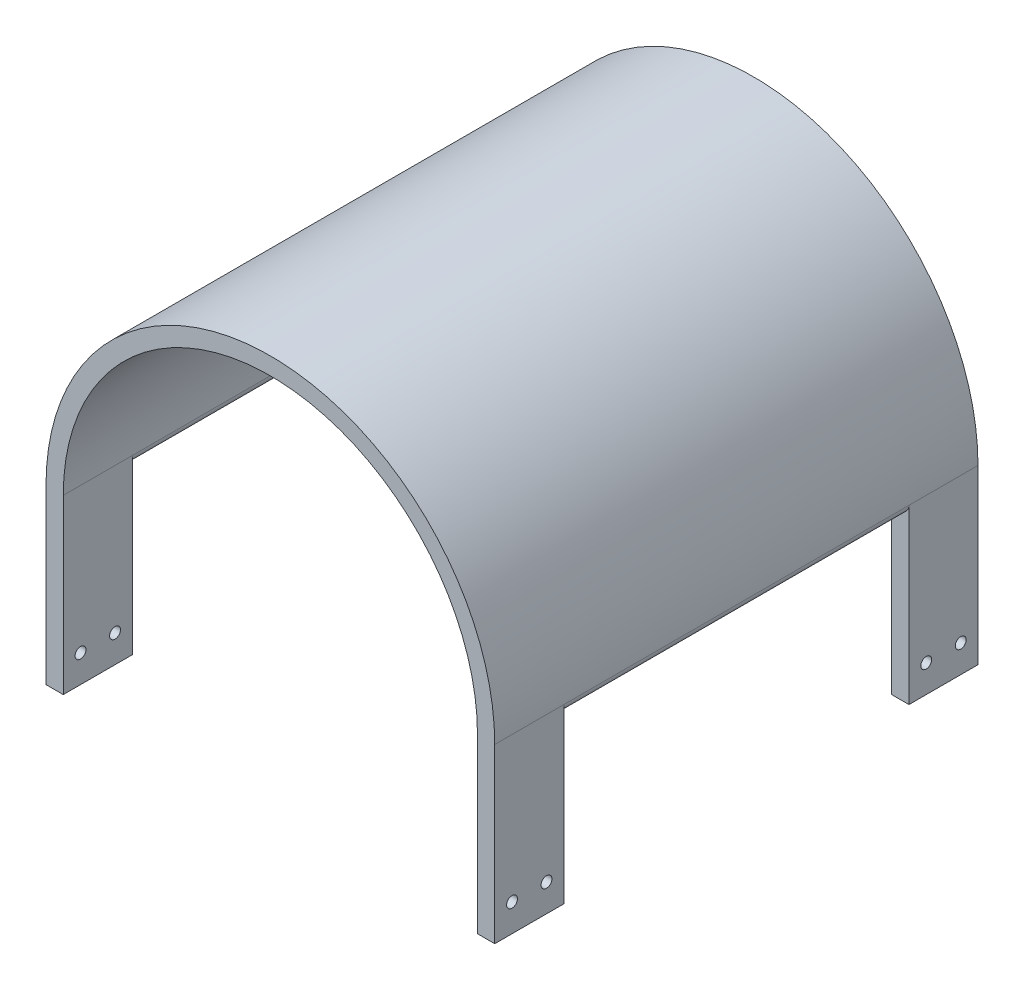
from build123d import *

# Parameters (mm, degrees)
EXTRUDE_THIN1_DEPTH     = 177.8
SKETCH7_W               = 6.35
SKETCH7_H               = 25.4
BOSS_EXTRUDE2_DEPTH     = 63.5
SKETCH11_R              = 2
CUT_EXTRUDE1_DEPTH      = 6.35
MIRROR2_COPY_1_SKETCH_W = 6.35
MIRROR2_COPY_1_SKETCH_H = 25.4
MIRROR2_COPY_1_DEPTH    = 63.5
MIRROR2_COPY_2_SKETCH_R = 2
MIRROR2_COPY_2_DEPTH    = 6.35
BOSS_EXTRUDE3_DEPTH     = 127


with BuildPart() as part:
    # Sketch2 → Extrude-Thin1 (new body)
    with BuildSketch(Plane.XY):
        with BuildLine():
            ThreePointArc((76.2, 23.522786699), (0, 99.722786699), (-76.2, 23.522786699))
            Line((-76.2, 23.522786699), (-82.55, 23.522786699))
            ThreePointArc((-82.55, 23.522786699), (0, 106.072786699), (82.55, 23.522786699))
            Line((82.55, 23.522786699), (76.2, 23.522786699))
        make_face()
    extrude(amount=EXTRUDE_THIN1_DEPTH)

    # Sketch7 → Boss-Extrude2 (add)
    with BuildSketch(Plane.XZ.offset(-23.522786699)):
        with Locations((79.375, 12.7)):
            Rectangle(SKETCH7_W, SKETCH7_H)
    boss_extrude2 = extrude(amount=BOSS_EXTRUDE2_DEPTH)

    # Sketch11 → Cut-Extrude1 (cut)
    with BuildSketch(Plane.ZY.offset(-76.2)):
        with Locations((6.35, -29.817213301)):
            Circle(SKETCH11_R)
        with Locations((19.05, -29.817213301)):
            Circle(SKETCH11_R)
    cut_extrude1 = extrude(amount=-CUT_EXTRUDE1_DEPTH, mode=Mode.SUBTRACT)

    # Mirror1: Boss-Extrude2, Cut-Extrude1 across plane
    add(boss_extrude2.mirror(Plane.XY.offset(88.9)))
    add(cut_extrude1.mirror(Plane.XY.offset(88.9)), mode=Mode.SUBTRACT)

    # Mirror2: Boss-Extrude2, Cut-Extrude1 across plane
    add(boss_extrude2.mirror(Plane(origin=(0, 0, 0), x_dir=(0, 0, 1), z_dir=(1, 0, 0))))
    add(cut_extrude1.mirror(Plane(origin=(0, 0, 0), x_dir=(0, 0, 1), z_dir=(1, 0, 0))), mode=Mode.SUBTRACT)

    # Mirror2 copy 1 sketch → Mirror2 copy 1 (add)
    with BuildSketch(Plane(origin=(0, 23.522786699, 177.8), x_dir=(-1, 0, 0), z_dir=(0, -1, 0))):
        with Locations((79.375, 12.7)):
            Rectangle(MIRROR2_COPY_1_SKETCH_W, MIRROR2_COPY_1_SKETCH_H)
    extrude(amount=MIRROR2_COPY_1_DEPTH)

    # Mirror2 copy 2 sketch → Mirror2 copy 2 (cut)
    with BuildSketch(Plane(origin=(-76.2, 0, 177.8), x_dir=(0, 0, -1), z_dir=(1, 0, 0))):
        with Locations((6.35, -29.817213301)):
            Circle(MIRROR2_COPY_2_SKETCH_R)
        with Locations((19.05, -29.817213301)):
            Circle(MIRROR2_COPY_2_SKETCH_R)
    extrude(amount=-MIRROR2_COPY_2_DEPTH, mode=Mode.SUBTRACT)

    # Sketch15 → Boss-Extrude3 (add)
    with BuildSketch(Plane.XY.offset(25.4)):
        with BuildLine():
            Line((76.2, 23.522786699), (82.55, 23.522786699))
            ThreePointArc((82.55, 23.522786699), (79.375, 20.347786699), (76.2, 23.522786699))
        make_face()
    boss_extrude3 = extrude(amount=BOSS_EXTRUDE3_DEPTH)

    # Mirror3: Boss-Extrude3 across plane
    add(boss_extrude3.mirror(Plane(origin=(0, 0, 0), x_dir=(0, 0, 1), z_dir=(1, 0, 0))))


solid = part.part
